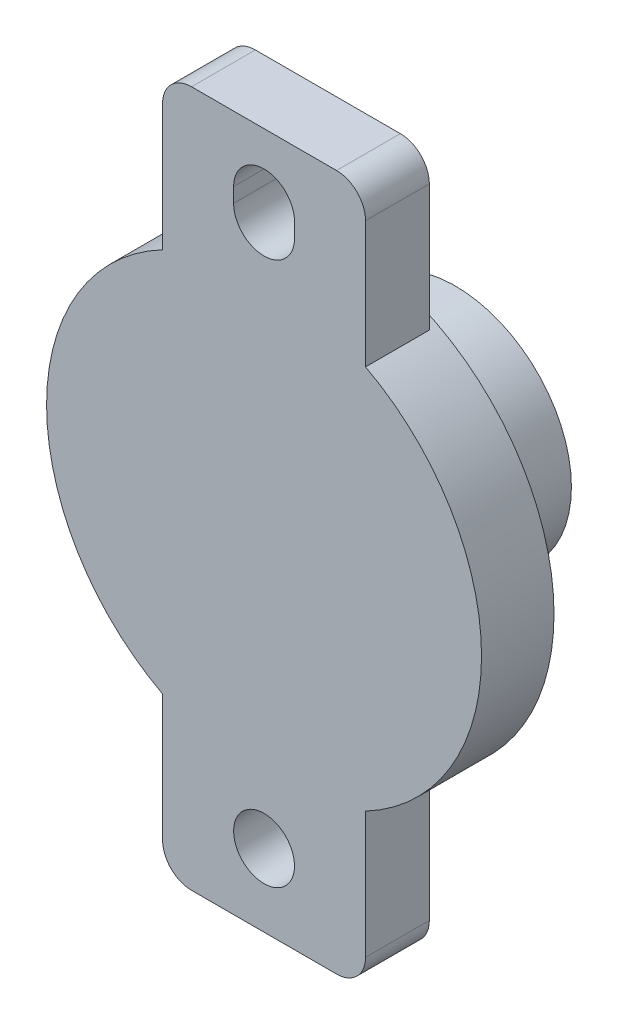
from build123d import *

# Parameters (mm, degrees)
BOSS_EXTRUDE1_DEPTH = 2.2
SKETCH2_R           = 7.5
BOSS_EXTRUDE2_DEPTH = 2.5
SKETCH3_R           = 1.05
CUT_EXTRUDE1_DEPTH  = 15.320963655
CUT_EXTRUDE2_REACH  = 16.321
FILLET1_R           = 1
SKETCH5_R           = 4
BOSS_EXTRUDE3_DEPTH = 3.7
BOSS_EXTRUDE4_DEPTH = 4.1


with BuildPart() as part:
    # Sketch1 → Boss-Extrude1 (new body)
    with BuildSketch(Plane.XY):
        with BuildLine():
            Line((-3.5, 12), (3.5, 12))
            Line((3.5, 12), (3.5, 6.633249581))
            ThreePointArc((3.5, 6.633249581), (7.5, 0), (3.5, -6.633249581))
            Line((3.5, -6.633249581), (3.5, -12))
            Line((3.5, -12), (-3.5, -12))
            Line((-3.5, -12), (-3.5, -6.633249581))
            ThreePointArc((-3.5, -6.633249581), (-7.5, 0), (-3.5, 6.633249581))
            Line((-3.5, 6.633249581), (-3.5, 12))
        make_face()
    extrude(amount=BOSS_EXTRUDE1_DEPTH)

    # Sketch2 → Boss-Extrude2 (add)
    with BuildSketch(Plane.XY.offset(2.2)):
        with Locations(Location((0, 0, 0), (0, 0, 242.181860715))):
            Circle(SKETCH2_R)
    extrude(amount=-BOSS_EXTRUDE2_DEPTH)

    # Sketch3 → Cut-Extrude1 (cut, through all)
    with BuildSketch(Plane(origin=(0, 0, 0), x_dir=(-1, 0, 0), z_dir=(0, 0, -1))):
        with Locations((0, -9.5)):
            Circle(SKETCH3_R)
    extrude(amount=-CUT_EXTRUDE1_DEPTH, mode=Mode.SUBTRACT)

    # Sketch4 → Cut-Extrude2 (cut, up to next)
    with BuildSketch(Plane(origin=(0, 0, 0), x_dir=(-1, 0, 0), z_dir=(0, 0, -1)), mode=Mode.PRIVATE) as cut_extrude2_sk1:
        with BuildLine():
            Line((1.05, 9.745840475), (1.05, 9.245840475))
            ThreePointArc((1.05, 9.245840475), (0, 8.195840475), (-1.05, 9.245840475))
            Line((-1.05, 9.245840475), (-1.05, 9.745840475))
            ThreePointArc((-1.05, 9.745840475), (0, 10.795840475), (1.05, 9.745840475))
        make_face()
    cut_extrude2_tool1 = extrude(cut_extrude2_sk1.sketch, amount=-CUT_EXTRUDE2_REACH, mode=Mode.PRIVATE) & part.part
    add(cut_extrude2_tool1.solids().sort_by_distance((0, 9.49584, 0))[0], mode=Mode.SUBTRACT)

    # Fillet1
    fillet1_edges = [part.edges().sort_by_distance(p)[0] for p in [
        (-3.5, 12, 1.1),
        (3.5, 12, 1.1),
        (3.5, -12, 1.1),
        (-3.5, -12, 1.1),
    ]]
    fillet(fillet1_edges, radius=FILLET1_R)



with BuildPart() as body_2:
    # Sketch5 → Boss-Extrude3 (new body)
    with BuildSketch(Plane.XY.offset(-4.4)):
        Circle(SKETCH5_R)
    extrude(amount=BOSS_EXTRUDE3_DEPTH)


with BuildPart() as part_1:
    add(part.part)

    add(body_2.part)  # Boss-Extrude4 merges body 2
    # Sketch6 → Boss-Extrude4 (add)
    with BuildSketch(Plane.XY.offset(-4.4)):
        with BuildLine():
            Line((-1.295183385, 1.25), (1.295183385, 1.25))
            ThreePointArc((1.295183385, 1.25), (1.8, 0), (1.295183385, -1.25))
            Line((1.295183385, -1.25), (-1.295183385, -1.25))
            ThreePointArc((-1.295183385, -1.25), (-1.8, 0), (-1.295183385, 1.25))
        make_face()
    extrude(amount=BOSS_EXTRUDE4_DEPTH)


solid = part_1.part
